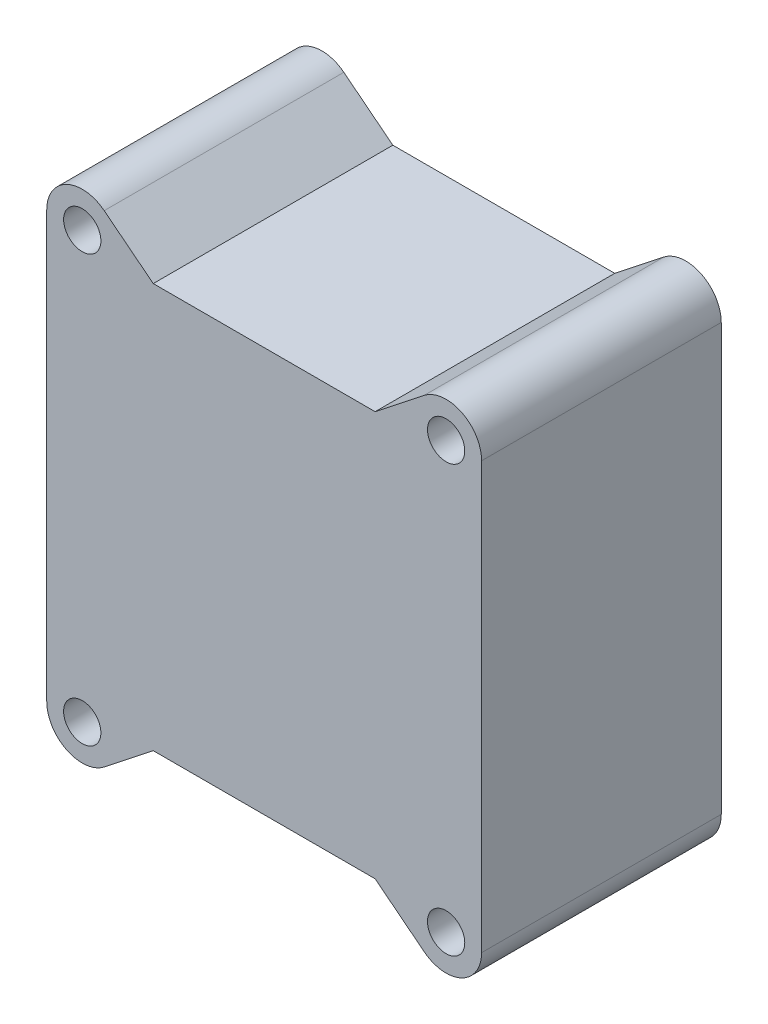
from build123d import *

# Parameters (mm, degrees)
SKIZZE1_R                        = 3
AUFSATZ_KAMERA_HALTERUNG_DEPTH   = 3
AUFSATZ_KAMERA_HALTERUNG_2_DEPTH = 3
AUFSATZ_KAMERA_HALTERUNG_3_DEPTH = 3
AUFSATZ_KAMERA_HALTERUNG_4_DEPTH = 3
SKIZZE2_W                        = 43
SKIZZE2_H                        = 40
DECKEL_DEPTH                     = 3
SKIZZE3_R                        = 1.7
L_CHER_KAMERA_HALTERUNG_DEPTH    = 4
SKIZZE4_W                        = 49
SKIZZE4_H                        = 45.581395348
SKIZZE4_W_2                      = 43
SKIZZE4_H_2                      = 40
AUFSATZ_LINEAR_AUSTRAGEN1_DEPTH  = 27
SKIZZE6_W                        = 25
SKIZZE6_H                        = 3
SCHNITT_LINEAR_AUSTRAGEN1_DEPTH  = 2.790698
SKIZZE7_R                        = 4
AUFSATZ_LINEAR_AUSTRAGEN2_DEPTH  = 27
SKIZZE8_R                        = 2.1
SCHNITT_LINEAR_AUSTRAGEN2_DEPTH  = 5.7
SKIZZE9_W                        = 0.18718111
SKIZZE9_H                        = 1.209302326
AUFSATZ_LINEAR_AUSTRAGEN3_DEPTH  = 27
SKIZZE10_R                       = 2.1
SCHNITT_LINEAR_AUSTRAGEN3_DEPTH  = 5.7
SKIZZE11_R                       = 3
AUFSATZ_LINEAR_AUSTRAGEN4_DEPTH  = 6
SKIZZE12_R                       = 1.7
SCHNITT_LINEAR_AUSTRAGEN4_DEPTH  = 4
FASE1_SIZE                       = 2
FASE1_SIZE2                      = 5.494954839


with BuildPart() as part:
    # Skizze1 → Aufsatz Kamera Halterung (new body)
    with BuildSketch(Plane.XY):
        with Locations((10.5, -3.5)):
            Circle(SKIZZE1_R)
    extrude(amount=AUFSATZ_KAMERA_HALTERUNG_DEPTH)



with BuildPart() as body_2:
    # Skizze1 → Aufsatz Kamera Halterung 2 (new body)
    with BuildSketch(Plane.XY):
        with Locations((10.5, 10)):
            Circle(SKIZZE1_R)
    extrude(amount=AUFSATZ_KAMERA_HALTERUNG_2_DEPTH)


with BuildPart() as body_3:
    # Skizze1 → Aufsatz Kamera Halterung 3 (new body)
    with BuildSketch(Plane.XY):
        with Locations((-10.5, 10)):
            Circle(SKIZZE1_R)
    extrude(amount=AUFSATZ_KAMERA_HALTERUNG_3_DEPTH)


with BuildPart() as body_4:
    # Skizze1 → Aufsatz Kamera Halterung 4 (new body)
    with BuildSketch(Plane.XY):
        with Locations((-10.5, -3.5)):
            Circle(SKIZZE1_R)
    extrude(amount=AUFSATZ_KAMERA_HALTERUNG_4_DEPTH)


with BuildPart() as part_1:
    add(part.part)

    add(body_2.part)  # Deckel merges body 2

    add(body_3.part)  # Deckel merges body 3

    add(body_4.part)  # Deckel merges body 4
    # Skizze2 → Deckel (add)
    with BuildSketch(Plane.XY.offset(3)):
        with Locations((0, 4)):
            Rectangle(SKIZZE2_W, SKIZZE2_H)
    extrude(amount=DECKEL_DEPTH)

    # Skizze3 → Löcher Kamera Halterung (cut)
    with BuildSketch(Plane(origin=(0, 0, 0), x_dir=(-1, 0, 0), z_dir=(0, 0, -1))):
        with Locations((10.5, 10)):
            Circle(SKIZZE3_R)
        with Locations((10.5, -3.5)):
            Circle(SKIZZE3_R)
        with Locations((-10.5, -3.5)):
            Circle(SKIZZE3_R)
        with Locations((-10.5, 10)):
            Circle(SKIZZE3_R)
    extrude(amount=-L_CHER_KAMERA_HALTERUNG_DEPTH, mode=Mode.SUBTRACT)

    # Skizze4 → Aufsatz-Linear austragen1 (add)
    with BuildSketch(Plane.XY.offset(6)):
        with Locations((0, 4)):
            Rectangle(SKIZZE4_W, SKIZZE4_H)
        with Locations((0, 4)):
            Rectangle(SKIZZE4_W_2, SKIZZE4_H_2, mode=Mode.SUBTRACT)
    extrude(amount=-AUFSATZ_LINEAR_AUSTRAGEN1_DEPTH)

    # Skizze6 → Schnitt-Linear austragen1 (cut)
    with BuildSketch(Plane(origin=(0, -18.790697674, 0), x_dir=(-1, 0, 0), z_dir=(0, -1, 0))):
        with Locations((0, 2)):
            Rectangle(SKIZZE6_W, SKIZZE6_H)
    extrude(amount=-SCHNITT_LINEAR_AUSTRAGEN1_DEPTH, mode=Mode.SUBTRACT)

    # Skizze7 → Aufsatz-Linear austragen2 (add, through all)
    with BuildSketch(Plane(origin=(0, 0, -21), x_dir=(-1, 0, 0), z_dir=(0, 0, -1))):
        with Locations((-20.5, 28)):
            Circle(SKIZZE7_R)
        with Locations((20.5, 28)):
            Circle(SKIZZE7_R)
        with Locations((20.5, -20)):
            Circle(SKIZZE7_R)
        with Locations((-20.5, -20)):
            Circle(SKIZZE7_R)
    extrude(amount=-AUFSATZ_LINEAR_AUSTRAGEN2_DEPTH)

    # Skizze8 → Schnitt-Linear austragen2 (cut)
    with BuildSketch(Plane(origin=(0, 0, -21), x_dir=(-1, 0, 0), z_dir=(0, 0, -1))):
        with Locations((-20.5, 28)):
            Circle(SKIZZE8_R)
        with Locations((20.5, 28)):
            Circle(SKIZZE8_R)
        with Locations((20.5, -20)):
            Circle(SKIZZE8_R)
        with Locations((-20.5, -20)):
            Circle(SKIZZE8_R)
    extrude(amount=-SCHNITT_LINEAR_AUSTRAGEN2_DEPTH, mode=Mode.SUBTRACT)

    # Skizze9 → Aufsatz-Linear austragen3 (add, through all)
    with BuildSketch(Plane(origin=(0, 0, -21), x_dir=(-1, 0, 0), z_dir=(0, 0, -1))):
        with Locations((-24.406409445, 27.395348837)):
            Rectangle(SKIZZE9_W, SKIZZE9_H)
        with Locations((24.406409445, 27.395348837)):
            Rectangle(SKIZZE9_W, SKIZZE9_H)
        with Locations((24.406409445, -19.395348837)):
            Rectangle(SKIZZE9_W, SKIZZE9_H)
        with Locations((-24.406409445, -19.395348837)):
            Rectangle(SKIZZE9_W, SKIZZE9_H)
        with BuildLine():
            Line((-18.024994038, 31.142347131), (-12.5, 26.790697674))
            Line((-12.5, 26.790697674), (-16.68718111, 26.790697674))
            ThreePointArc((-16.68718111, 26.790697674), (-16.676598558, 29.175415421), (-18.024994038, 31.142347131))
        make_face()
        with BuildLine():
            Line((12.5, 26.790697674), (16.68718111, 26.790697674))
            ThreePointArc((16.68718111, 26.790697674), (16.676598558, 29.175415421), (18.024994038, 31.142347131))
            Line((18.024994038, 31.142347131), (12.5, 26.790697674))
        make_face()
        with BuildLine():
            Line((18.024994038, -23.142347131), (12.5, -18.790697674))
            Line((12.5, -18.790697674), (16.68718111, -18.790697674))
            ThreePointArc((16.68718111, -18.790697674), (16.676598558, -21.175415421), (18.024994038, -23.142347131))
        make_face()
        with BuildLine():
            Line((-12.5, -18.790697674), (-16.68718111, -18.790697674))
            ThreePointArc((-16.68718111, -18.790697674), (-16.676598558, -21.175415421), (-18.024994038, -23.142347131))
            Line((-18.024994038, -23.142347131), (-12.5, -18.790697674))
        make_face()
    extrude(amount=-AUFSATZ_LINEAR_AUSTRAGEN3_DEPTH)

    # Skizze10 → Schnitt-Linear austragen3 (cut)
    with BuildSketch(Plane.XY.offset(6)):
        with Locations((-20.5, 28)):
            Circle(SKIZZE10_R)
        with Locations((20.5, 28)):
            Circle(SKIZZE10_R)
        with Locations((20.5, -20)):
            Circle(SKIZZE10_R)
        with Locations((-20.5, -20)):
            Circle(SKIZZE10_R)
    extrude(amount=-SCHNITT_LINEAR_AUSTRAGEN3_DEPTH, mode=Mode.SUBTRACT)

    # Skizze11 → Aufsatz-Linear austragen4 (add)
    with BuildSketch(Plane.ZY.offset(24.5)):
        with Locations((-15.2, -14.85)):
            Circle(SKIZZE11_R)
    extrude(amount=AUFSATZ_LINEAR_AUSTRAGEN4_DEPTH)

    # Skizze12 → Schnitt-Linear austragen4 (cut)
    with BuildSketch(Plane.ZY.offset(30.5)):
        with Locations((-15.2, -14.85)):
            Circle(SKIZZE12_R)
    extrude(amount=-SCHNITT_LINEAR_AUSTRAGEN4_DEPTH, mode=Mode.SUBTRACT)

    # Fase1
    fase1_edges = [part_1.edges().sort_by_distance(p)[0] for p in [
        (-24.5, -14.85, -18.2),
    ]]
    fase1_side = [part_1.faces().sort_by_distance(p)[0] for p in [
        (-24.5, 4.443247545, -7.318938669),
    ]]
    chamfer(fase1_edges, length=FASE1_SIZE, length2=FASE1_SIZE2, reference=fase1_side[0])


solid = part_1.part
